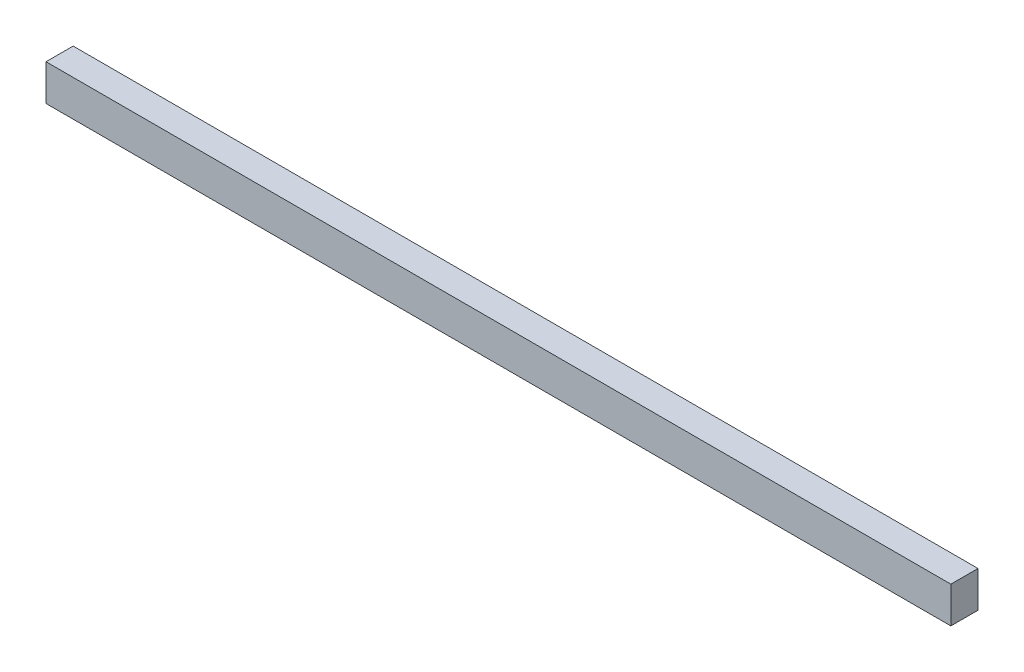
from build123d import *

# Parameters (mm, degrees)
SKETCH_1_W      = 75
SKETCH_1_H      = 100
EXTRUDE_1_DEPTH = 2500


with BuildPart() as part:
    # Эскиз1 → Бобышка-Вытянуть1 (new body)
    with BuildSketch(Plane(origin=(0, 0, 0), x_dir=(0, 0, -1), z_dir=(1, 0, 0))):
        Rectangle(SKETCH_1_W, SKETCH_1_H)
    extrude(amount=EXTRUDE_1_DEPTH)


solid = part.part
